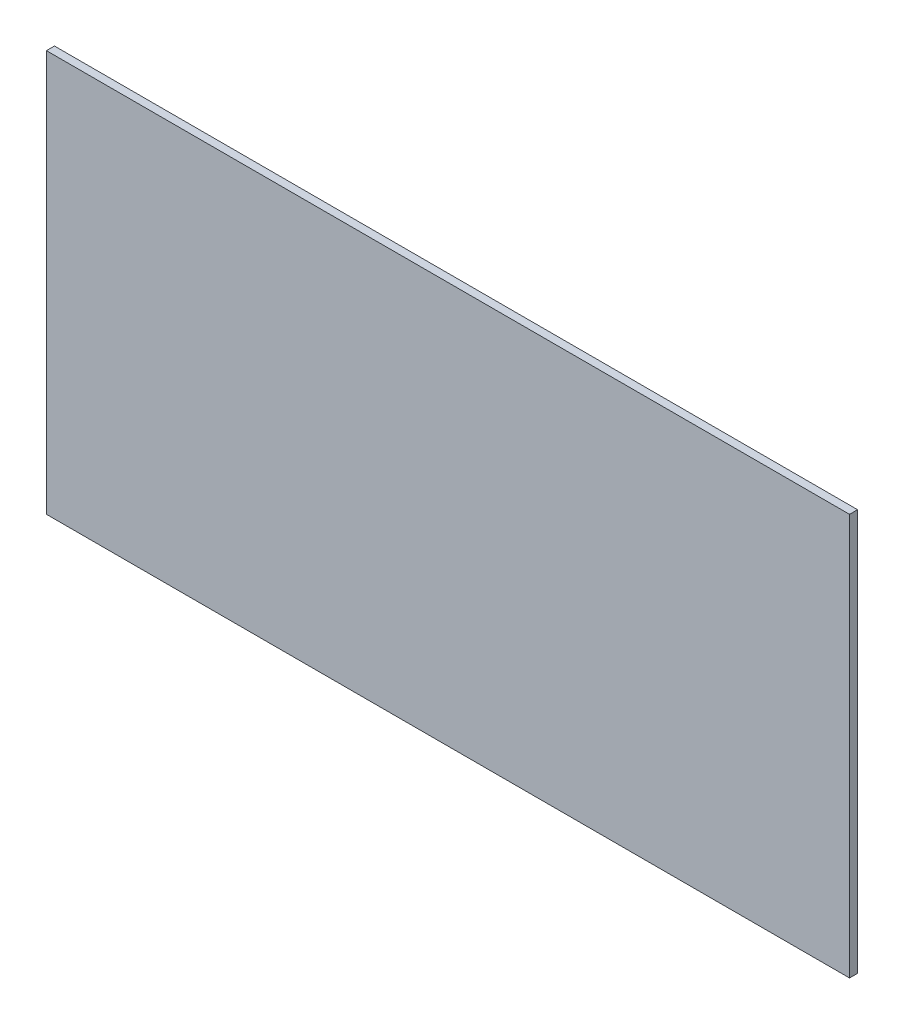
from build123d import *

# Parameters (mm, degrees)
SKETCH1_W           = 400
SKETCH1_H           = 200
BOSS_EXTRUDE1_DEPTH = 4


with BuildPart() as part:
    # Sketch1 → Boss-Extrude1 (new body)
    with BuildSketch(Plane.XY):
        with Locations((200, 100)):
            Rectangle(SKETCH1_W, SKETCH1_H)
    extrude(amount=BOSS_EXTRUDE1_DEPTH)


solid = part.part
